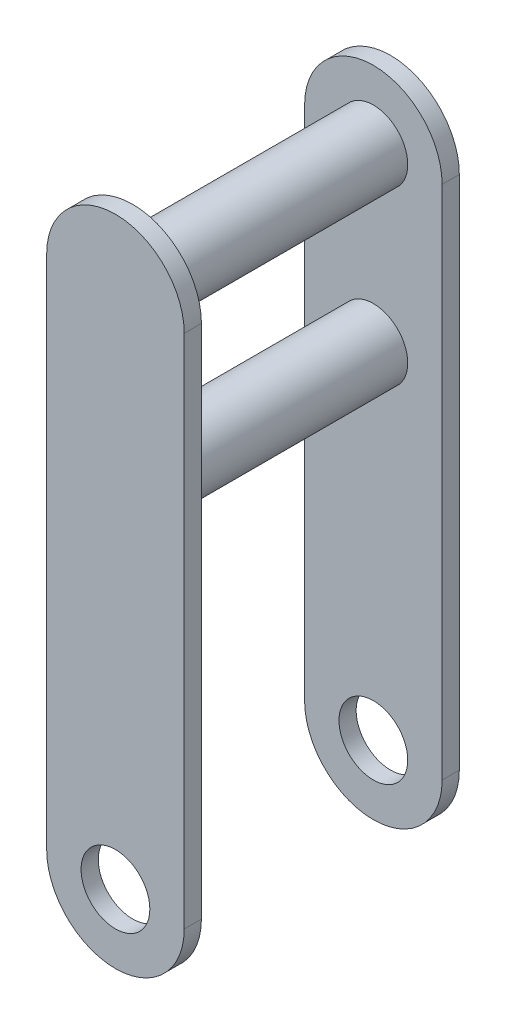
from build123d import *

# Parameters (mm, degrees)
BOSS_EXTRUDE1_START = 75
SKETCH1_R           = 20
BOSS_EXTRUDE1_DEPTH = 5
SKETCH2_R           = 20
BOSS_EXTRUDE2_DEPTH = 140


with BuildPart() as part:
    # Sketch1 → Boss-Extrude1 (new body, symmetric)
    with BuildSketch(Plane.XY.offset(BOSS_EXTRUDE1_START)):
        with BuildLine():
            Line((-40, 0), (-40, 300))
            ThreePointArc((-40, 300), (0, 340), (40, 300))
            Line((40, 300), (40, 0))
            ThreePointArc((40, 0), (0, -40), (-40, 0))
        make_face()
        Circle(SKETCH1_R, mode=Mode.SUBTRACT)
    boss_extrude1 = extrude(amount=BOSS_EXTRUDE1_DEPTH, both=True)

    # Sketch2 → Boss-Extrude2 (add)
    with BuildSketch(Plane(origin=(0, 0, 70), x_dir=(-1, 0, 0), z_dir=(0, 0, -1))):
        with Locations((0, 300)):
            Circle(SKETCH2_R)
        with Locations((0, 200)):
            Circle(SKETCH2_R)
    extrude(amount=BOSS_EXTRUDE2_DEPTH)

    # Mirror2: Boss-Extrude1 across plane
    add(boss_extrude1.mirror(Plane.XY))


solid = part.part
